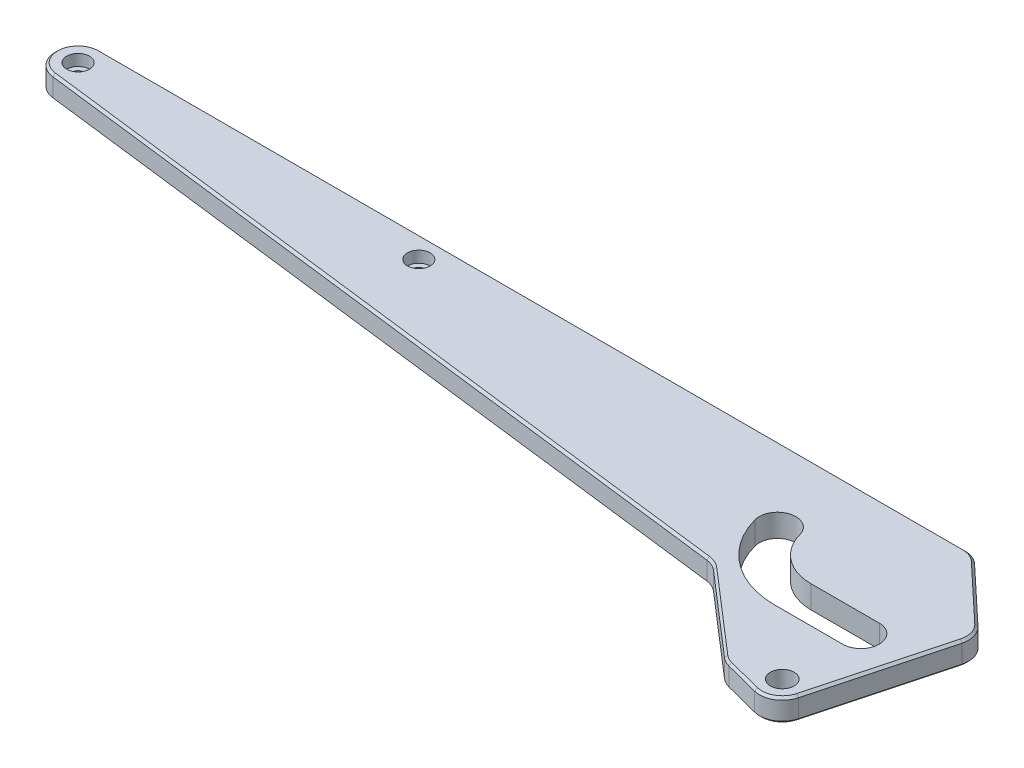
from build123d import *

# Parameters (mm, degrees)
BOSS_EXTRUDE1_DEPTH              = 5
SLOT_DEPTH                       = 11
F_10_5_10_5_DIAMETER_HOLE1_D     = 10.5
F_10_5_10_5_DIAMETER_HOLE1_DEPTH = 15
F_10_5_10_5_DIAMETER_HOLE1_TIP   = 3.15451825
CBORE_FOR_M5_SHCS1_D             = 5.5
CBORE_FOR_M5_SHCS1_DEPTH         = 15
CBORE_FOR_M5_SHCS1_CBORE_D       = 10
CBORE_FOR_M5_SHCS1_CBORE_DEPTH   = 5
CBORE_FOR_M5_SHCS1_TIP           = 1.652366702
CUT_EXTRUDE3_DEPTH               = 11
FILLET1_R                        = 10
CHAMFER1_SIZE                    = 1


with BuildPart() as part:
    # Sketch1 → Boss-Extrude1 (new body, symmetric)
    with BuildSketch(Plane(origin=(0, 0, 0), x_dir=(1, 0, 0), z_dir=(0, 1, 0))):
        with BuildLine():
            Line((-390, 90), (34.468189123, 90))
            Line((34.468189123, 90), (9.659258263, -2.588190451))
            ThreePointArc((9.659258263, -2.588190451), (5.03987296, -8.63711066), (-2.499017827, -9.682711908))
            Line((-2.499017827, -9.682711908), (-20, -5.16587129))
            Line((-20, -5.16587129), (-60, 29.405996647))
            Line((-60, 29.405996647), (-391.218693434, 70.074538484))
            ThreePointArc((-391.218693434, 70.074538484), (-399.981347984, 80.610485395), (-390, 90))
        make_face()
    extrude(amount=BOSS_EXTRUDE1_DEPTH, both=True)

    # Sketch4 → Slot (cut, through all)
    with BuildSketch(Plane(origin=(0, 5, 0), x_dir=(1, 0, 0), z_dir=(0, 1, 0))):
        with BuildLine():
            Line((-30, 26.591016), (0, 26.591016))
            ThreePointArc((0, 26.591016), (8.05, 34.641016), (0, 42.691016))
            Line((0, 42.691016), (-30, 42.691016))
            ThreePointArc((-30, 42.691016), (-43.362313367, 47.226910181), (-51.202071887, 58.95993796))
            ThreePointArc((-51.202071887, 58.95993796), (-61.061268102, 64.652147549), (-66.75347769, 54.792951334))
            ThreePointArc((-66.75347769, 54.792951334), (-53.163372374, 34.453921402), (-30, 26.591016))
        make_face()
    extrude(amount=-SLOT_DEPTH, mode=Mode.SUBTRACT)

    # Ø10.5 (10.5) Diameter Hole1
    with Locations(Plane(origin=(0, 5, 0), x_dir=(1, 0, 0), z_dir=(0, 1, 0))):
        with Locations((0, 0)):
            Hole(F_10_5_10_5_DIAMETER_HOLE1_D / 2, depth=F_10_5_10_5_DIAMETER_HOLE1_DEPTH)
            with Locations((0, 0, -(F_10_5_10_5_DIAMETER_HOLE1_DEPTH + F_10_5_10_5_DIAMETER_HOLE1_TIP / 2))):  # 118° drill point
                Cone(0, F_10_5_10_5_DIAMETER_HOLE1_D / 2, F_10_5_10_5_DIAMETER_HOLE1_TIP, mode=Mode.SUBTRACT)

    # CBORE for M5 SHCS1
    with Locations(Plane(origin=(0, 5, 0), x_dir=(1, 0, 0), z_dir=(0, 1, 0))):
        with Locations((-390, 80), (-240, 80)):
            CounterBoreHole(CBORE_FOR_M5_SHCS1_D / 2, CBORE_FOR_M5_SHCS1_CBORE_D / 2, CBORE_FOR_M5_SHCS1_CBORE_DEPTH, depth=CBORE_FOR_M5_SHCS1_DEPTH)
            with Locations((0, 0, -(CBORE_FOR_M5_SHCS1_DEPTH + CBORE_FOR_M5_SHCS1_TIP / 2))):  # 118° drill point
                Cone(0, CBORE_FOR_M5_SHCS1_D / 2, CBORE_FOR_M5_SHCS1_TIP, mode=Mode.SUBTRACT)

    # Sketch13 → Cut-Extrude3 (cut, through all)
    with BuildSketch(Plane(origin=(0, 5, 0), x_dir=(1, 0, 0), z_dir=(0, 1, 0))):
        Polygon((-5.531810877, 90), (34.468189123, 90), (26.42971335, 60), align=None)
    extrude(amount=-CUT_EXTRUDE3_DEPTH, mode=Mode.SUBTRACT)

    # Fillet1
    fillet1_edges = [part.edges().sort_by_distance(p)[0] for p in [
        (-20, 0, 5.16587129),
        (-60, 0, -29.405996647),
        (26.42971335, 0, -60),
        (-5.531810877, 0, -90),
    ]]
    fillet(fillet1_edges, radius=FILLET1_R)

    # Chamfer1
    chamfer1_edges = [part.edges().sort_by_distance(p)[0] for p in [
        (-399.981347984, -5, -80.610485395),
        (5.03987296, 5, 8.63711066),
        (17.26978309, 5, -25.814674877),
        (-399.981347984, 5, -80.610485395),
        (9.709435896, 5, -75.694130232),
        (9.709435896, -5, -75.694130232),
        (-199.744878532, 5, -90),
        (-39.735397279, 5, -11.891367421),
        (17.26978309, -5, -25.814674877),
        (-10.11553696, 5, 7.716959206),
        (-19.874383451, 5, 4.92614185),
        (24.83814676, 5, -59.546431893),
        (-5.80958377, 5, -89.298189314),
        (-199.744878532, -5, -90),
        (-10.11553696, -5, 7.716959206),
        (5.03987296, -5, 8.63711066),
        (-39.735397279, -5, -11.891367421),
        (-19.874383451, -5, 4.92614185),
        (24.83814676, -5, -59.546431893),
        (-5.80958377, -5, -89.298189314),
        (-60.183408772, -5, -28.992469299),
        (-227.118878147, 5, -49.925614719),
        (-60.183408772, 5, -28.992469299),
        (-227.118878147, -5, -49.925614719),
    ]]
    chamfer(chamfer1_edges, length=CHAMFER1_SIZE)


solid = part.part
